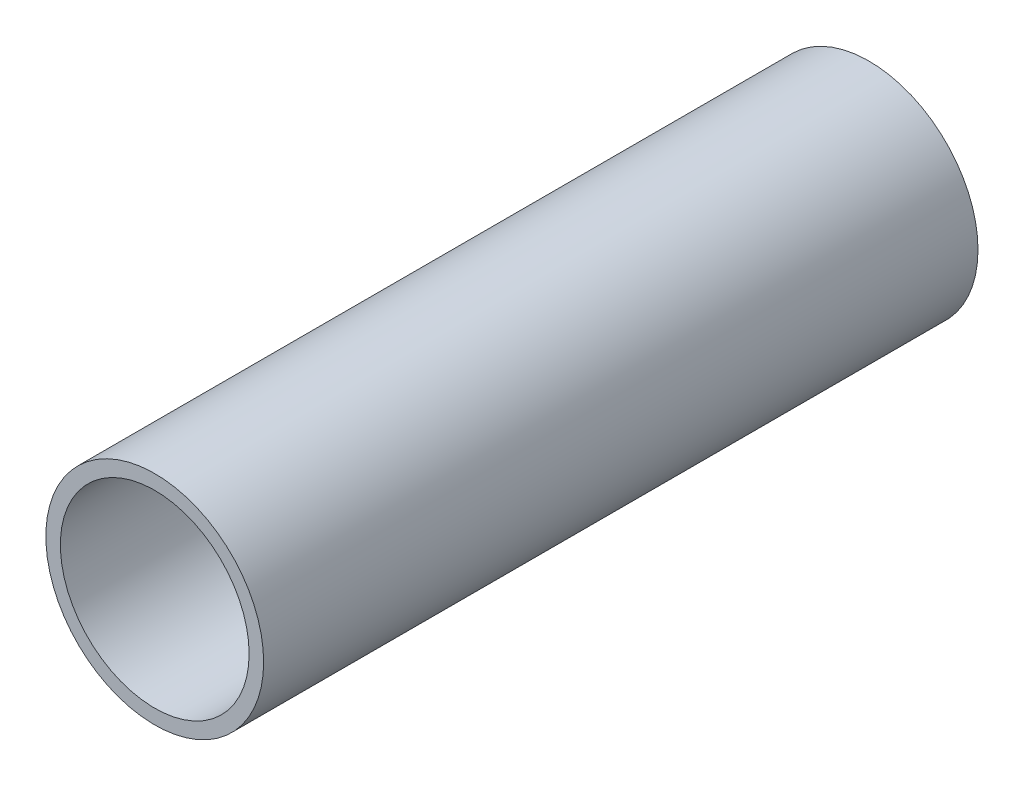
from build123d import *

# Parameters (mm, degrees)
SKETCH1_R           = 9.525
SKETCH1_R_2         = 8.255
BOSS_EXTRUDE1_DEPTH = 62.484


with BuildPart() as part:
    # Sketch1 → Boss-Extrude1 (new body)
    with BuildSketch(Plane.XY):
        Circle(SKETCH1_R)
        Circle(SKETCH1_R_2, mode=Mode.SUBTRACT)
    extrude(amount=BOSS_EXTRUDE1_DEPTH)


solid = part.part
